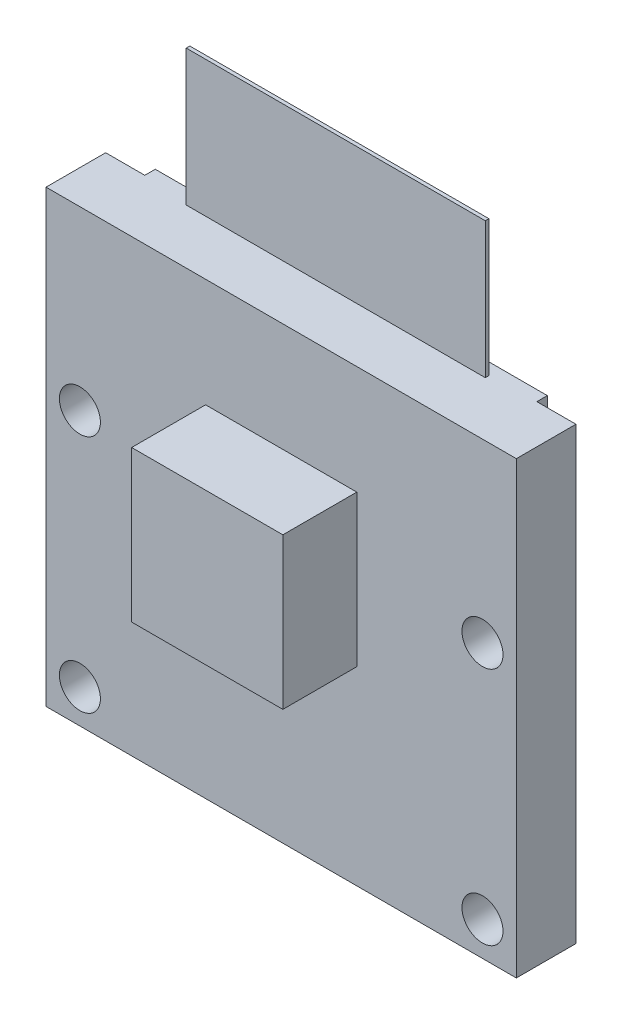
from build123d import *

# Parameters (mm, degrees)
SKETCH1_W           = 25.0444
SKETCH1_H           = 23.9522
BOSS_EXTRUDE1_DEPTH = 3.175
SKETCH2_R           = 1.0922
CUT_EXTRUDE1_DEPTH  = 3.175
SKETCH3_W           = 8.0518
SKETCH3_H           = 8.0518
BOSS_EXTRUDE2_DEPTH = 3.937
SKETCH4_W           = 20.8788
SKETCH4_H           = 5.5372
BOSS_EXTRUDE3_DEPTH = 0.5588
SKETCH5_W           = 15.9258
SKETCH5_H           = 0.191961024
BOSS_EXTRUDE4_DEPTH = 7.239


with BuildPart() as part:
    # Sketch1 → Boss-Extrude1 (new body)
    with BuildSketch(Plane.XY):
        with Locations((-13.304877678, 12.887280749)):
            Rectangle(SKETCH1_W, SKETCH1_H)
    extrude(amount=BOSS_EXTRUDE1_DEPTH)

    # Sketch2 → Cut-Extrude1 (cut)
    with BuildSketch(Plane.XY.offset(3.175)):
        with Locations((-2.586077678, 2.714580749)):
            Circle(SKETCH2_R)
        with Locations((-2.586077678, 15.465380749)):
            Circle(SKETCH2_R)
        with Locations((-24.023677678, 2.714580749)):
            Circle(SKETCH2_R)
        with Locations((-24.023677678, 15.465380749)):
            Circle(SKETCH2_R)
    extrude(amount=-CUT_EXTRUDE1_DEPTH, mode=Mode.SUBTRACT)

    # Sketch3 → Boss-Extrude2 (add)
    with BuildSketch(Plane.XY.offset(3.175)):
        with Locations((-13.304877678, 15.046280749)):
            Rectangle(SKETCH3_W, SKETCH3_H)
    extrude(amount=BOSS_EXTRUDE2_DEPTH)

    # Sketch4 → Boss-Extrude3 (add)
    with BuildSketch(Plane(origin=(0, 0, 0), x_dir=(-1, 0, 0), z_dir=(0, 0, -1))):
        with Locations((13.304877678, 22.094780749)):
            Rectangle(SKETCH4_W, SKETCH4_H)
    extrude(amount=BOSS_EXTRUDE3_DEPTH)

    # Sketch5 → Boss-Extrude4 (add)
    with BuildSketch(Plane(origin=(0, 24.863380749, 0), x_dir=(1, 0, 0), z_dir=(0, 1, 0))):
        with Locations((-13.304877678, -0.172180512)):
            Rectangle(SKETCH5_W, SKETCH5_H)
    extrude(amount=BOSS_EXTRUDE4_DEPTH)


solid = part.part
